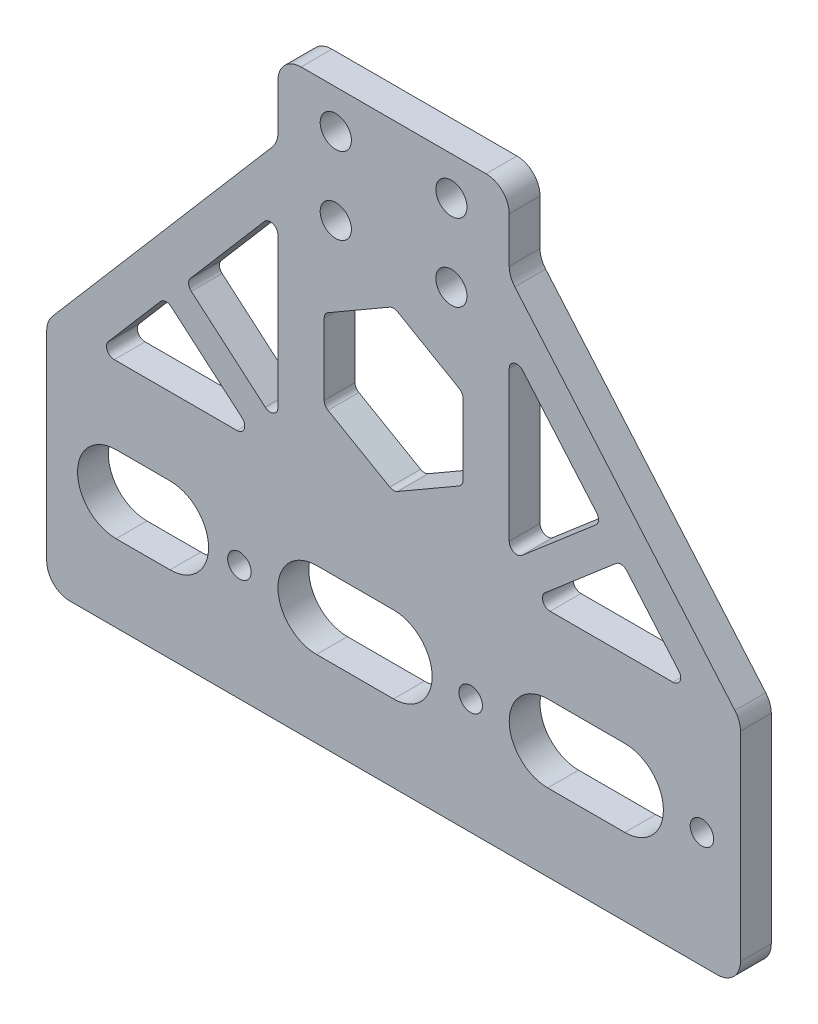
from build123d import *

# Parameters (mm, degrees)
EXTRUDE_1_DEPTH          = 4
EXTRUDE_2_DEPTH          = 4
CUT_EXTRUDE_2_DEPTH      = 4
CUT_EXTRUDE_3_DEPTH      = 4
SKETCH_8_R               = 1.525
CUT_EXTRUDE_4_DEPTH      = 10
SKETCH_9_R               = 2.025
CUT_EXTRUDE_5_DEPTH      = 10
CUT_EXTRUDE_6_DEPTH      = 1
CUT_EXTRUDE_6_DEPTH_BACK = 5
SKETCH_11_W              = 30
SKETCH_11_H              = 10
SKETCH_11_R              = 2.025
EXTRUDE_3_DEPTH          = 4
FILLET_2_R               = 3
EXTRUDE_4_DEPTH          = 4
FILLET_3_R               = 1


with BuildPart() as part:
    # 草图1 → 凸台-拉伸1 (new body)
    with BuildSketch(Plane.XY):
        Polygon((-45, 0), (45, 0), (45, 30), (15, 30), (15, 65), (-15, 65), (-15, 30), (-45, 30), align=None)
    extrude(amount=EXTRUDE_1_DEPTH)

    # 草图4 → 凸台-拉伸2 (add)
    with BuildSketch(Plane.XY.offset(4)):
        Polygon((-45, 30), (-15, 65), (-15, 30), align=None)
        Polygon((15, 65), (45, 30), (15, 30), align=None)
    extrude(amount=-EXTRUDE_2_DEPTH)

    # 草图5 → 切除-拉伸2 (cut)
    with BuildSketch(Plane.XY.offset(4)):
        Polygon((-38.414611102, 30), (-15, 30), (-15, 57.317046286), align=None)
        Polygon((15, 57.317046286), (38.414611102, 30), (15, 30), align=None)
    extrude(amount=-CUT_EXTRUDE_2_DEPTH, mode=Mode.SUBTRACT)

    # 草图6 → 切除-拉伸3 (cut)
    with BuildSketch(Plane.XY.offset(4)):
        Polygon((0, 54.050827988), (-9, 48.854675566), (-9, 38.46237072), (0, 33.266218297), (9, 38.46237072), (9, 48.854675566), align=None)
    extrude(amount=-CUT_EXTRUDE_3_DEPTH, mode=Mode.SUBTRACT)

    # 草图8 → 切除-拉伸4 (cut)
    with BuildSketch(Plane(origin=(0, 0, 0), x_dir=(-1, 0, 0), z_dir=(0, 0, -1))):
        with Locations((20.000000001, 14.999999905)):
            Circle(SKETCH_8_R)
        with Locations((-9.999999999, 14.999999905)):
            Circle(SKETCH_8_R)
        with Locations((-39.999999999, 14.999999905)):
            Circle(SKETCH_8_R)
    extrude(amount=-CUT_EXTRUDE_4_DEPTH, mode=Mode.SUBTRACT)

    # 草图9 → 切除-拉伸5 (cut)
    with BuildSketch(Plane(origin=(0, 0, 0), x_dir=(-1, 0, 0), z_dir=(0, 0, -1))):
        with Locations((-7.5, 60)):
            Circle(SKETCH_9_R)
        with Locations((7.5, 60)):
            Circle(SKETCH_9_R)
    extrude(amount=-CUT_EXTRUDE_5_DEPTH, mode=Mode.SUBTRACT)

    # 草图10 → 切除-拉伸6 (cut, two sides)
    with BuildSketch(Plane.XY.offset(4)) as cut_extrude_6_sk:
        with BuildLine():
            Line((-10.000000001, 19.999999905), (-1e-09, 19.999999905))
            ThreePointArc((-1e-09, 19.999999905), (4.999999999, 14.999999905), (-1e-09, 9.999999905))
            Line((-1e-09, 9.999999905), (-10.000000001, 9.999999905))
            ThreePointArc((-10.000000001, 9.999999905), (-15.000000001, 14.999999905), (-10.000000001, 19.999999905))
        make_face()
        with BuildLine():
            Line((19.999999999, 19.999999905), (29.999999999, 19.999999905))
            ThreePointArc((29.999999999, 19.999999905), (34.999999999, 14.999999905), (29.999999999, 9.999999905))
            Line((29.999999999, 9.999999905), (19.999999999, 9.999999905))
            ThreePointArc((19.999999999, 9.999999905), (14.999999999, 14.999999905), (19.999999999, 19.999999905))
        make_face()
        with BuildLine():
            Line((-36, 19.999999905), (-29, 19.999999905))
            ThreePointArc((-29, 19.999999905), (-24, 14.999999905), (-29, 9.999999905))
            Line((-29, 9.999999905), (-36, 9.999999905))
            ThreePointArc((-36, 9.999999905), (-41, 14.999999905), (-36, 19.999999905))
        make_face()
    extrude(amount=CUT_EXTRUDE_6_DEPTH, mode=Mode.SUBTRACT)
    extrude(cut_extrude_6_sk.sketch, amount=-CUT_EXTRUDE_6_DEPTH_BACK, mode=Mode.SUBTRACT)

    # 草图11 → 凸台-拉伸3 (add)
    with BuildSketch(Plane.XY.offset(4)):
        with Locations((0, 70)):
            Rectangle(SKETCH_11_W, SKETCH_11_H)
        with Locations((7.5, 70)):
            Circle(SKETCH_11_R, mode=Mode.SUBTRACT)
        with Locations((-7.5, 70)):
            Circle(SKETCH_11_R, mode=Mode.SUBTRACT)
    extrude(amount=-EXTRUDE_3_DEPTH)

    # 圆角2
    fillet_2_edges = [part.edges().sort_by_distance(p)[0] for p in [
        (-45, 30, 2),
        (-15, 65, 2),
        (15, 65, 2),
        (45, 30, 2),
        (45, 0, 2),
        (-45, 0, 2),
        (15, 75, 2),
        (-15, 75, 2),
    ]]
    fillet(fillet_2_edges, radius=FILLET_2_R)

    # 草图13 → 凸台-拉伸4 (add)
    with BuildSketch(Plane.XY.offset(4)):
        Polygon((15, 33.037026409), (26.997186292, 43.320328945), (29.600351786, 40.283302536), (17.603165494, 30), (15, 30), align=None)
    extrude_4 = extrude(amount=-EXTRUDE_4_DEPTH)

    # 镜向1: 凸台-拉伸4 across plane
    add(extrude_4.mirror(Plane(origin=(0, 0, 0), x_dir=(0, 0, 1), z_dir=(1, 0, 0))))

    # 圆角3
    fillet_3_edges = [part.edges().sort_by_distance(p)[0] for p in [
        (15, 33.037026409, 2),
        (26.997186292, 43.320328945, 2),
        (29.600351786, 40.283302536, 2),
        (17.603165494, 30, 2),
        (-26.997186292, 43.320328945, 2),
        (-29.600351786, 40.283302536, 2),
        (-17.603165494, 30, 2),
        (-15, 33.037026409, 2),
        (-38.414611102, 30, 2),
        (-15, 57.317046286, 2),
        (15, 57.317046286, 2),
        (38.414611102, 30, 2),
        (0, 54.050827988, 2),
        (9, 48.854675566, 2),
        (9, 38.46237072, 2),
        (0, 33.266218297, 2),
        (-9, 38.46237072, 2),
        (-9, 48.854675566, 2),
    ]]
    fillet(fillet_3_edges, radius=FILLET_3_R)


solid = part.part
